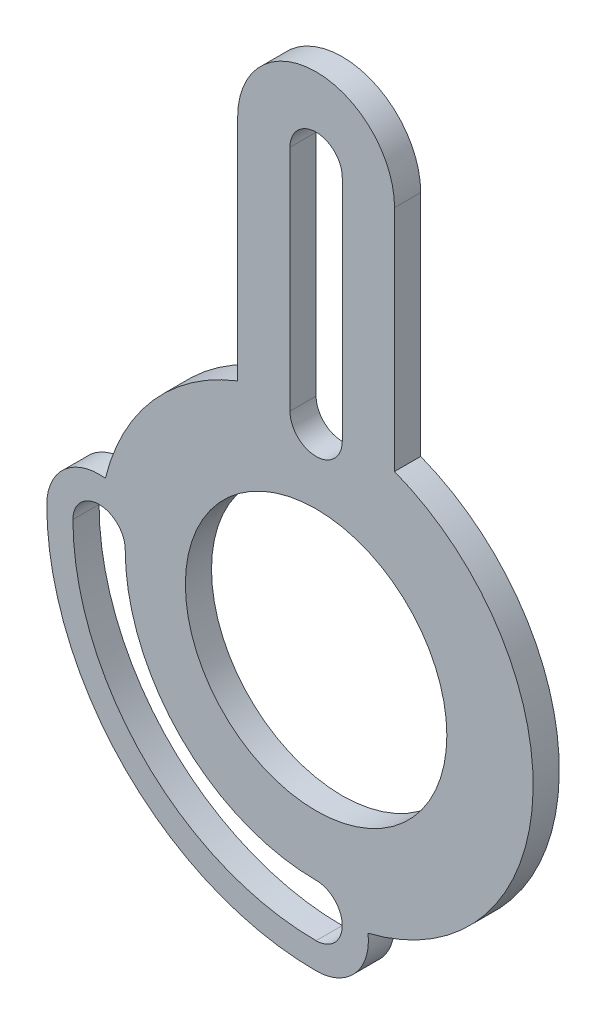
from build123d import *

# Parameters (mm, degrees)
SKETCH2_R           = 25
BOSS_EXTRUDE1_DEPTH = 5


with BuildPart() as part:
    # Sketch2 → Boss-Extrude1 (new body)
    with BuildSketch(Plane.XY):
        with BuildLine():
            Line((15, 82.39), (15, 38.694314828))
            ThreePointArc((15, 38.694314828), (41.414681799, -2.659723947), (9.927155207, -40.295180723))
            ThreePointArc((9.927155207, -40.295180723), (7.484924608, -48.131432999), (0, -51.5))
            ThreePointArc((0, -51.5), (-36.415999231, -36.415999231), (-51.5, 0))
            ThreePointArc((-51.5, 0), (-48.131432999, 7.484924608), (-40.295180723, 9.927155207))
            ThreePointArc((-40.295180723, 9.927155207), (-31.16531118, 27.403893502), (-15, 38.694314828))
            Line((-15, 38.694314828), (-15, 82.39))
            ThreePointArc((-15, 82.39), (0, 97.39), (15, 82.39))
        make_face()
        Circle(SKETCH2_R, mode=Mode.SUBTRACT)
        with BuildLine():
            Line((-5, 38.69), (-5, 82.39))
            ThreePointArc((-5, 82.39), (0, 87.39), (5, 82.39))
            Line((5, 82.39), (5, 38.69))
            ThreePointArc((5, 38.69), (0, 33.69), (-5, 38.69))
        make_face(mode=Mode.SUBTRACT)
        with BuildLine():
            ThreePointArc((-46.5, 0), (-32.880465325, -32.880465325), (0, -46.5))
            ThreePointArc((0, -46.5), (5, -41.5), (0, -36.5))
            ThreePointArc((0, -36.5), (-25.809397513, -25.809397513), (-36.5, 0))
            ThreePointArc((-36.5, 0), (-41.5, 5), (-46.5, 0))
        make_face(mode=Mode.SUBTRACT)
    extrude(amount=BOSS_EXTRUDE1_DEPTH)


solid = part.part
